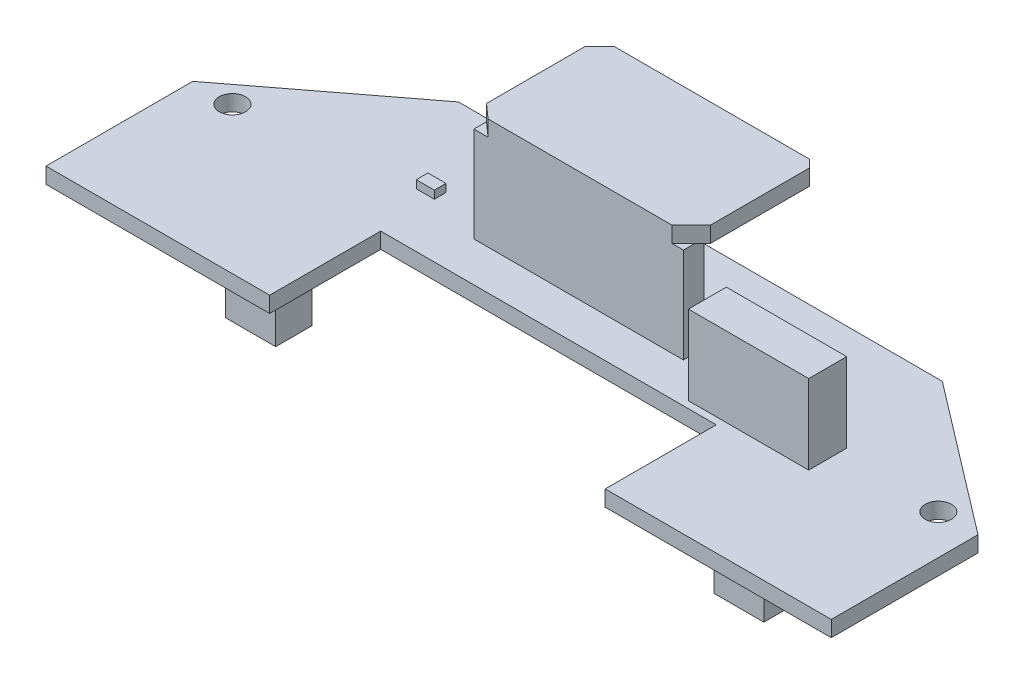
from build123d import *

# Parameters (mm, degrees)
ESBO_O1_R                = 1.65
RESSALTO_EXTRUS_O1_DEPTH = 2
ESBO_O1_3_W              = 6.3
ESBO_O1_3_H              = 4.6
RESSALTO_EXTRUS_O2_DEPTH = 10
ESBO_O2_W                = 26.421659043
ESBO_O2_H                = 2.598510054
RESSALTO_EXTRUS_O3_DEPTH = 12
RESSALTO_EXTRUS_O4_DEPTH = 2
ESBO_O4_W                = 15.168134441
ESBO_O4_H                = 4.790416537
RESSALTO_EXTRUS_O5_DEPTH = 10
ESBO_O5_W                = 2.278476724
ESBO_O5_H                = 1.465715939
RESSALTO_EXTRUS_O6_DEPTH = 1


with BuildPart() as part:
    # Esboço1 → Ressalto-extrusão1 (new body)
    with BuildSketch(Plane(origin=(0, 0, 0), x_dir=(1, 0, 0), z_dir=(0, 1, 0))):
        Polygon((-49.5, 2), (-30.5, 16.5), (30.5, 16.5), (49.5, 2), (49.5, -16.5), (21, -16.5), (21, -2.5), (-21.3, -2.5), (-21.3, -16.5), (-49.5, -16.5), align=None)
        with Locations((-44.5, 2)):
            Circle(ESBO_O1_R, mode=Mode.SUBTRACT)
        with Locations((44.5, 2)):
            Circle(ESBO_O1_R, mode=Mode.SUBTRACT)
    extrude(amount=RESSALTO_EXTRUS_O1_DEPTH)

    # Esboço1<3> → Ressalto-extrusão2 (add)
    with BuildSketch(Plane(origin=(0, 0, 0), x_dir=(1, 0, 0), z_dir=(0, 1, 0))):
        with Locations((-30.45, -7.45)):
            Rectangle(ESBO_O1_3_W, ESBO_O1_3_H)
        with Locations((-10.8, 10.25)):
            Rectangle(ESBO_O1_3_W, ESBO_O1_3_H)
        with Locations((10.2, 10.25)):
            Rectangle(ESBO_O1_3_W, ESBO_O1_3_H)
        with Locations((30.4, -6.75)):
            Rectangle(ESBO_O1_3_W, ESBO_O1_3_H)
    extrude(amount=-RESSALTO_EXTRUS_O2_DEPTH)

    # Esboço2 → Ressalto-extrusão3 (add)
    with BuildSketch(Plane(origin=(0, 2, 0), x_dir=(1, 0, 0), z_dir=(0, 1, 0))):
        with Locations((-1.359424961, 3.810785195)):
            Rectangle(ESBO_O2_W, ESBO_O2_H)
    extrude(amount=RESSALTO_EXTRUS_O3_DEPTH)

    # Esboço3 → Ressalto-extrusão4 (add)
    with BuildSketch(Plane(origin=(0, 14, 0), x_dir=(1, 0, 0), z_dir=(0, 1, 0))):
        Polygon((-12.779725254, 2.511530168), (10.40079667, 2.511530168), (12.833618236, 4.944351733), (12.833618236, 17.396051346), (11.851404561, 18.378265021), (-12.779725254, 18.378265021), (-14.570254482, 16.587735794), (-14.570254482, 4.107082692), align=None)
    extrude(amount=RESSALTO_EXTRUS_O4_DEPTH)

    # Esboço4 → Ressalto-extrusão5 (add)
    with BuildSketch(Plane(origin=(0, 2, 0), x_dir=(1, 0, 0), z_dir=(0, 1, 0))):
        with Locations((24.193900659, 0.772233303)):
            Rectangle(ESBO_O4_W, ESBO_O4_H)
    extrude(amount=RESSALTO_EXTRUS_O5_DEPTH)

    # Esboço5 → Ressalto-extrusão6 (add)
    with BuildSketch(Plane(origin=(0, 2, 0), x_dir=(1, 0, 0), z_dir=(0, 1, 0))):
        with Locations((-22.531195516, 5.087051721)):
            Rectangle(ESBO_O5_W, ESBO_O5_H)
    extrude(amount=RESSALTO_EXTRUS_O6_DEPTH)


solid = part.part
